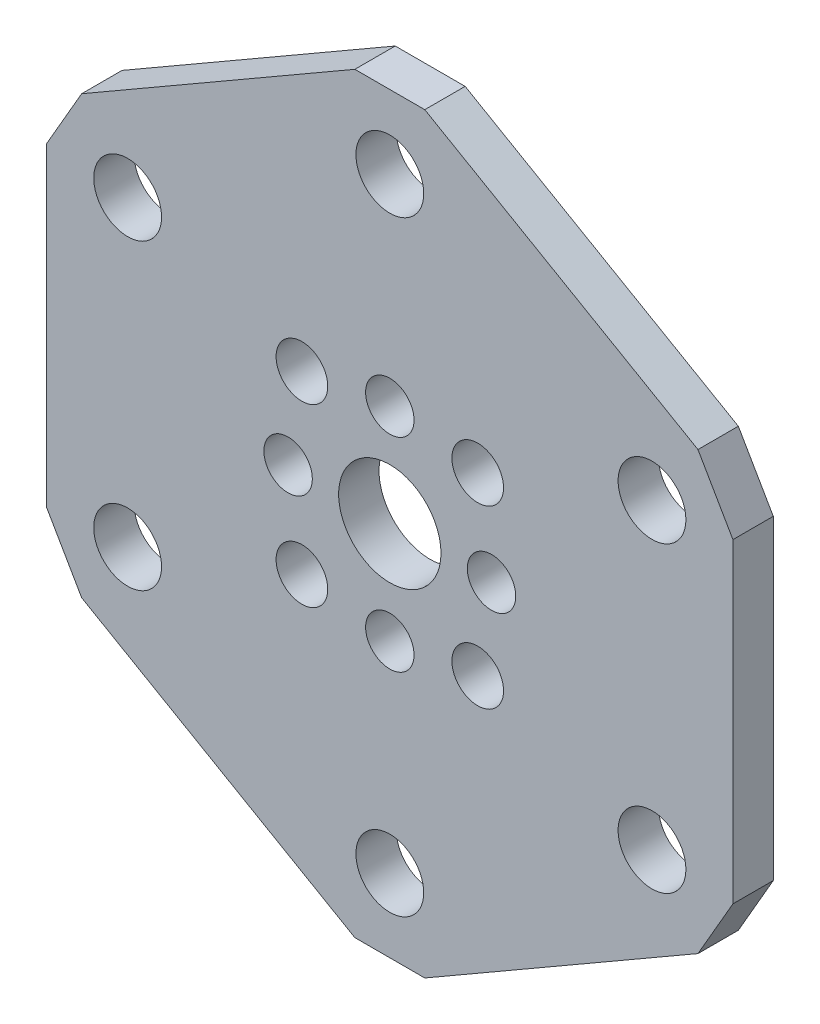
from build123d import *

# Parameters (mm, degrees)
SKETCH1_R           = 2.667
SKETCH1_R_2         = 1.905
SKETCH1_R_3         = 4.025
SKETCH1_R_4         = 2.032
BOSS_EXTRUDE1_DEPTH = 3.175


with BuildPart() as part:
    # Sketch1 → Boss-Extrude1 (new body)
    with BuildSketch(Plane(origin=(0, 0, 0), x_dir=(-1, 0, 0), z_dir=(0, 0, -1))):
        Polygon((2.749630657, 29.57498078), (-2.749630657, 29.57498078), (-24.237869343, 17.16874039), (-26.9875, 12.40624039), (-26.9875, -12.40624039), (-24.237869343, -17.16874039), (-2.749630657, -29.57498078), (2.749630657, -29.57498078), (24.237869343, -17.16874039), (26.9875, -12.40624039), (26.9875, 12.40624039), (24.237869343, 17.16874039), align=None)
        with Locations((20.622229928, 11.90625)):
            Circle(SKETCH1_R, mode=Mode.SUBTRACT)
        with Locations((0, -23.8125)):
            Circle(SKETCH1_R, mode=Mode.SUBTRACT)
        with Locations((-20.622229928, 11.90625)):
            Circle(SKETCH1_R, mode=Mode.SUBTRACT)
        with Locations((0, -8)):
            Circle(SKETCH1_R_2, mode=Mode.SUBTRACT)
        with Locations((0, 8)):
            Circle(SKETCH1_R_2, mode=Mode.SUBTRACT)
        with Locations((0, 23.8125)):
            Circle(SKETCH1_R, mode=Mode.SUBTRACT)
        Circle(SKETCH1_R_3, mode=Mode.SUBTRACT)
        with Locations((-8, 0)):
            Circle(SKETCH1_R_2, mode=Mode.SUBTRACT)
        with Locations((8, 0)):
            Circle(SKETCH1_R_2, mode=Mode.SUBTRACT)
        with Locations((-20.622229928, -11.90625)):
            Circle(SKETCH1_R, mode=Mode.SUBTRACT)
        with Locations((20.622229928, -11.90625)):
            Circle(SKETCH1_R, mode=Mode.SUBTRACT)
        with Locations((-6.914797213, 6.914797213)):
            Circle(SKETCH1_R_4, mode=Mode.SUBTRACT)
        with Locations((-6.914797213, -6.914797213)):
            Circle(SKETCH1_R_4, mode=Mode.SUBTRACT)
        with Locations((6.914797213, -6.914797213)):
            Circle(SKETCH1_R_4, mode=Mode.SUBTRACT)
        with Locations((6.914797213, 6.914797213)):
            Circle(SKETCH1_R_4, mode=Mode.SUBTRACT)
    extrude(amount=-BOSS_EXTRUDE1_DEPTH)


solid = part.part
